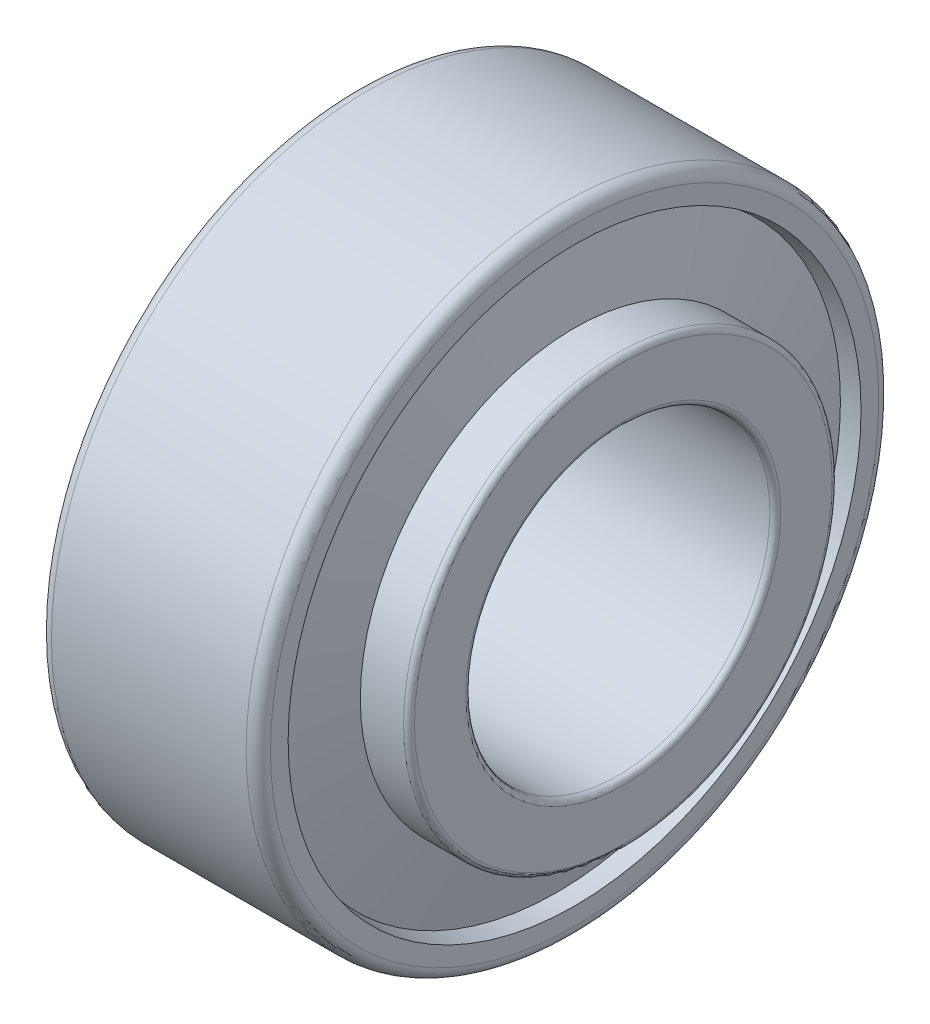
from build123d import *


with BuildPart() as part:
    # Эскиз1 → Повернуть1 (revolve)
    with BuildSketch(Plane.XY):
        with BuildLine():
            Line((1.755247843, 20.544620897), (0, 20.2205))
            Line((0, 20.2205), (0, 25))
            ThreePointArc((0, 25), (0.292893219, 25.707106781), (1, 26))
            Line((1, 26), (17, 26))
            ThreePointArc((17, 26), (17.707106781, 25.707106781), (18, 25))
            Line((18, 25), (18, 23.544347499))
            Line((18, 23.544347499), (16.568548211, 23.280018196))
            Line((16.568548211, 23.280018196), (18, 17.160981804))
            Line((18, 17.160981804), (18, 17.610981804))
            Line((18, 17.610981804), (21.55, 17.610981804))
            ThreePointArc((21.55, 17.610981804), (21.868198052, 17.479179856), (22, 17.160981804))
            Line((22, 17.160981804), (22, 12.95))
            ThreePointArc((22, 12.95), (21.868198052, 12.631801948), (21.55, 12.5))
            Line((21.55, 12.5), (0.45, 12.5))
            ThreePointArc((0.45, 12.5), (0.131801948, 12.631801948), (0, 12.95))
            Line((0, 12.95), (0, 13.041451381))
            Line((0, 13.041451381), (3.510495686, 13.041451381))
            Line((3.510495686, 13.041451381), (1.755247843, 20.544620897))
        make_face()
    revolve(axis=Axis((-882.527700014, 0, 0), (1, 0, 0)))


solid = part.part
